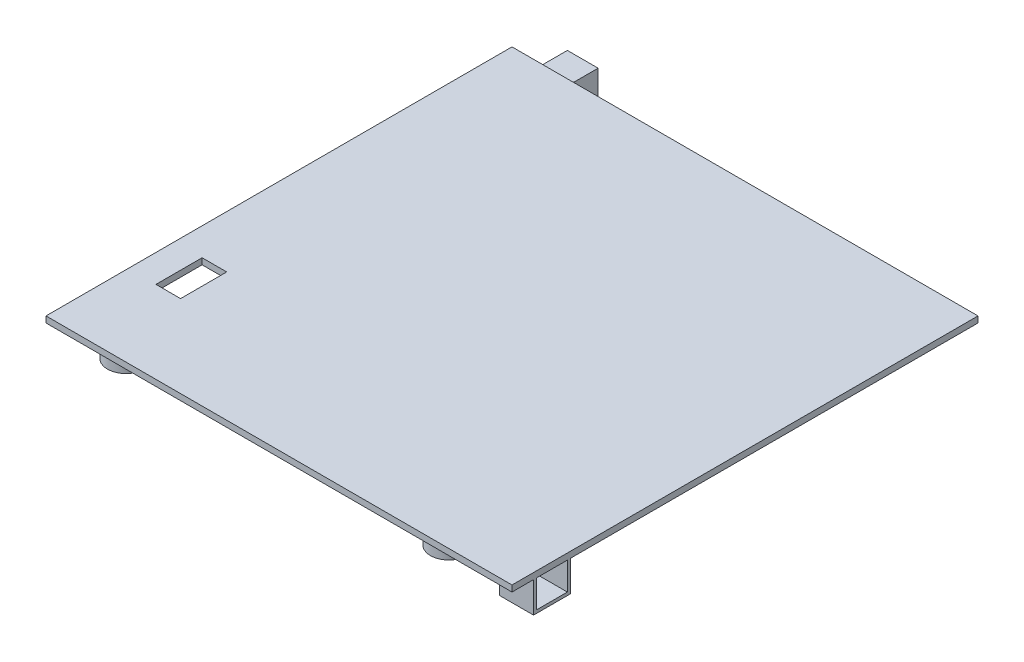
from build123d import *

# Parameters (mm, degrees)
SKETCH1_W            = 151.5
SKETCH1_H            = 151.5
BOSS_EXTRUDE1_DEPTH  = 2
SKETCH8_R            = 6
BOSS_EXTRUDE3_DEPTH  = 10
SKETCH9_R            = 5
CUT_EXTRUDE5_DEPTH   = 10
LPATTERN3_COUNT      = 2
LPATTERN3_PITCH      = 105
LPATTERN3_COUNT_DIR2 = 2
LPATTERN3_PITCH_DIR2 = 105
SKETCH10_W           = 10
SKETCH10_H           = 20
BOSS_EXTRUDE4_DEPTH  = 9
SKETCH11_W           = 11
SKETCH11_H           = 12
BOSS_EXTRUDE5_DEPTH  = 10
SKETCH13_W           = 10
SKETCH13_H           = 9
CUT_EXTRUDE6_DEPTH   = 10
SKETCH15_W           = 8
SKETCH15_H           = 15
CUT_EXTRUDE7_DEPTH   = 2


with BuildPart() as part:
    # Sketch1 → Boss-Extrude1 (new body)
    with BuildSketch(Plane(origin=(0, 0, 0), x_dir=(1, 0, 0), z_dir=(0, 1, 0))):
        with Locations((75.75, 75.75)):
            Rectangle(SKETCH1_W, SKETCH1_H)
    extrude(amount=BOSS_EXTRUDE1_DEPTH)

    # Sketch8 → Boss-Extrude3 (add)
    with BuildSketch(Plane(origin=(0, 0, 0), x_dir=(-1, 0, 0), z_dir=(0, -1, 0))):
        with Locations((-13, 13)):
            Circle(SKETCH8_R)
    boss_extrude3 = extrude(amount=BOSS_EXTRUDE3_DEPTH)

    # Sketch9 → Cut-Extrude5 (cut)
    with BuildSketch(Plane(origin=(0, 0, 0), x_dir=(1, 0, 0), z_dir=(0, 1, 0))):
        with Locations((13, 13)):
            Circle(SKETCH9_R)
    cut_extrude5 = extrude(amount=-CUT_EXTRUDE5_DEPTH, mode=Mode.SUBTRACT)

    # LPattern3: Boss-Extrude3, Cut-Extrude5 2 × 2
    with Locations(*[(i * LPATTERN3_PITCH, 0, -j * LPATTERN3_PITCH_DIR2) for i in range(LPATTERN3_COUNT) for j in range(LPATTERN3_COUNT_DIR2) if (i, j) != (0, 0)]):
        add(boss_extrude3)
        add(cut_extrude5, mode=Mode.SUBTRACT)

    # Sketch10 → Boss-Extrude4 (add)
    with BuildSketch(Plane(origin=(0, 0, 0), x_dir=(1, 0, 0), z_dir=(0, 1, 0))):
        with Locations((13, 151.5)):
            Rectangle(SKETCH10_W, SKETCH10_H)
    extrude(amount=-BOSS_EXTRUDE4_DEPTH)

    # Sketch11 → Boss-Extrude5 (add)
    with BuildSketch(Plane(origin=(0, 0, 0), x_dir=(-1, 0, 0), z_dir=(0, -1, 0))):
        with Locations((-146, 13)):
            Rectangle(SKETCH11_W, SKETCH11_H)
    extrude(amount=BOSS_EXTRUDE5_DEPTH)

    # Sketch13 → Cut-Extrude6 (cut)
    with BuildSketch(Plane(origin=(151.5, 0, 0), x_dir=(0, 0, -1), z_dir=(1, 0, 0))):
        with Locations((13, -4.5)):
            Rectangle(SKETCH13_W, SKETCH13_H)
    extrude(amount=-CUT_EXTRUDE6_DEPTH, mode=Mode.SUBTRACT)

    # Sketch15 → Cut-Extrude7 (cut)
    with BuildSketch(Plane(origin=(0, 0, 0), x_dir=(1, 0, 0), z_dir=(0, 1, 0))):
        with Locations((13, 34.25)):
            Rectangle(SKETCH15_W, SKETCH15_H)
    extrude(amount=CUT_EXTRUDE7_DEPTH, mode=Mode.SUBTRACT)


solid = part.part
